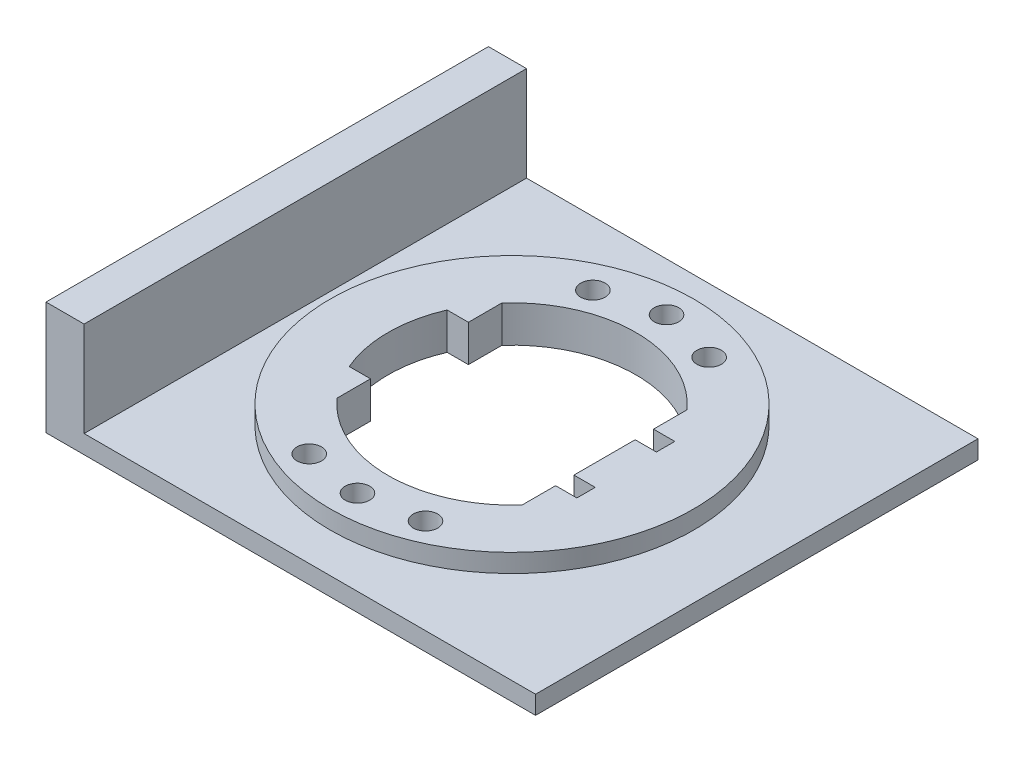
from build123d import *

# Parameters (mm, degrees)
SKETCH1_W           = 80
SKETCH1_H           = 72.3
BOSS_EXTRUDE1_DEPTH = 6
SKETCH2_W           = 80
SKETCH2_H           = 72.3
SKETCH2_R           = 29.705
CUT_EXTRUDE1_DEPTH  = 3
CUT_EXTRUDE3_DEPTH  = 7
SKETCH5_R           = 2
CUT_EXTRUDE4_DEPTH  = 7
SKETCH6_R           = 2
CUT_EXTRUDE5_DEPTH  = 7
SKETCH8_W           = 6.225749038
SKETCH8_H           = 72.3
BOSS_EXTRUDE2_DEPTH = 15.5


with BuildPart() as part:
    # Sketch1 → Boss-Extrude1 (new body)
    with BuildSketch(Plane(origin=(0, 0, 0), x_dir=(1, 0, 0), z_dir=(0, 1, 0))):
        with Locations((1.546657586, 37.660128709)):
            Rectangle(SKETCH1_W, SKETCH1_H)
    extrude(amount=BOSS_EXTRUDE1_DEPTH)

    # Sketch2 → Cut-Extrude1 (cut)
    with BuildSketch(Plane(origin=(0, 6, 0), x_dir=(-1, 0, 0), z_dir=(0, 1, 0))):
        with Locations((-1.546657586, -37.660128709)):
            Rectangle(SKETCH2_W, SKETCH2_H)
        with Locations((-1.546657586, -37.660128709)):
            Circle(SKETCH2_R, mode=Mode.SUBTRACT)
    extrude(amount=-CUT_EXTRUDE1_DEPTH, mode=Mode.SUBTRACT)

    # Sketch3 → Cut-Extrude3 (cut, through all)
    with BuildSketch(Plane(origin=(0, 6, 0), x_dir=(-1, 0, 0), z_dir=(0, 1, 0))):
        with BuildLine():
            ThreePointArc((-16.671348492, -51.125128709), (-1.546657586, -57.910128709), (13.57803332, -51.125128709))
            Line((13.57803332, -51.125128709), (13.57803332, -45.660128709))
            Line((13.57803332, -45.660128709), (17.056097586, -45.660128709))
            ThreePointArc((17.056097586, -45.660128709), (18.703342414, -37.660128709), (17.056097586, -29.660128709))
            Line((17.056097586, -29.660128709), (13.57803332, -29.660128709))
            Line((13.57803332, -29.660128709), (13.57803332, -24.195128709))
            ThreePointArc((13.57803332, -24.195128709), (-1.546657586, -17.410128709), (-16.671348492, -24.195128709))
            Line((-16.671348492, -24.195128709), (-16.671348492, -29.660128709))
            Line((-16.671348492, -29.660128709), (-20.149412759, -29.660128709))
            Line((-20.149412759, -29.660128709), (-20.149412759, -32.660128709))
            Line((-20.149412759, -32.660128709), (-16.671348492, -32.660128709))
            Line((-16.671348492, -32.660128709), (-16.671348492, -42.660128709))
            Line((-16.671348492, -42.660128709), (-20.149412759, -42.660128709))
            Line((-20.149412759, -42.660128709), (-20.149412759, -45.660128709))
            Line((-20.149412759, -45.660128709), (-16.671348492, -45.660128709))
            Line((-16.671348492, -45.660128709), (-16.671348492, -51.125128709))
        make_face()
    extrude(amount=-CUT_EXTRUDE3_DEPTH, mode=Mode.SUBTRACT)

    # Sketch5 → Cut-Extrude4 (cut, through all)
    with BuildSketch(Plane(origin=(0, 6, 0), x_dir=(-1, 0, 0), z_dir=(0, 1, 0))):
        with Locations((-1.546657586, -12.410128709)):
            Circle(SKETCH5_R)
        with Locations((-1.546657586, -62.910128709)):
            Circle(SKETCH5_R)
    extrude(amount=-CUT_EXTRUDE4_DEPTH, mode=Mode.SUBTRACT)

    # Sketch6 → Cut-Extrude5 (cut, through all)
    with BuildSketch(Plane(origin=(0, 6, 0), x_dir=(1, 0, 0), z_dir=(0, 1, 0))):
        with Locations((-7.953342414, 60.376565813)):
            Circle(SKETCH6_R)
        with Locations((11.046657586, 60.376565813)):
            Circle(SKETCH6_R)
        with Locations((11.046657586, 14.026565813)):
            Circle(SKETCH6_R)
        with Locations((-7.953342414, 14.026565813)):
            Circle(SKETCH6_R)
    extrude(amount=-CUT_EXTRUDE5_DEPTH, mode=Mode.SUBTRACT)

    # Sketch8 → Boss-Extrude2 (add)
    with BuildSketch(Plane(origin=(0, 3, 0), x_dir=(1, 0, 0), z_dir=(0, 1, 0))):
        with Locations((-35.340467895, 37.660128709)):
            Rectangle(SKETCH8_W, SKETCH8_H)
    extrude(amount=BOSS_EXTRUDE2_DEPTH)


solid = part.part
